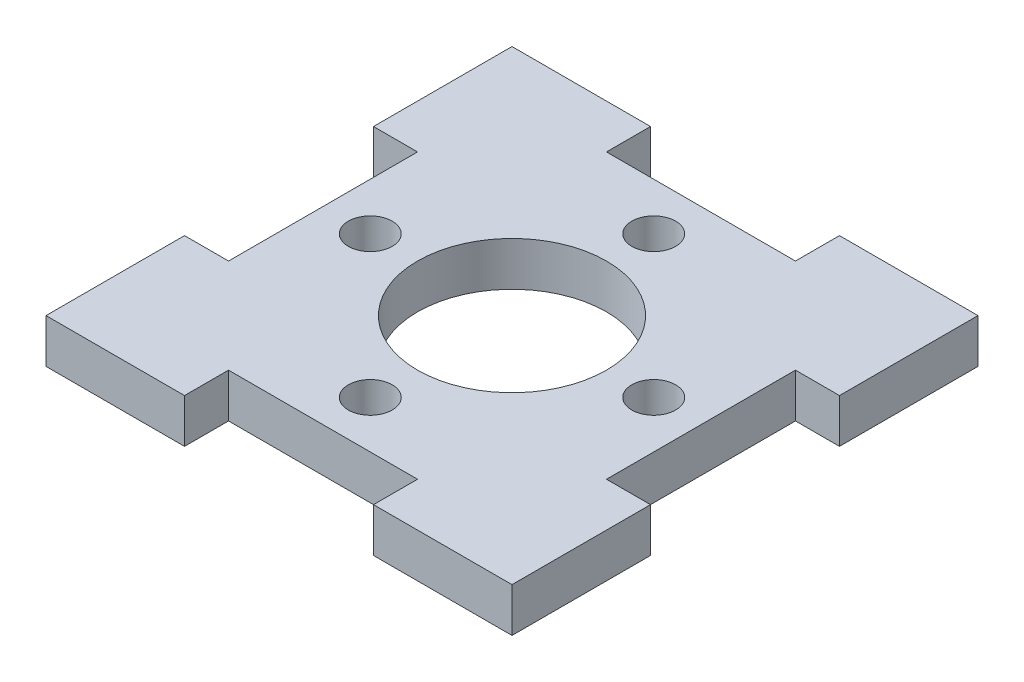
from build123d import *

# Parameters (mm, degrees)
SKETCH1_R                 = 6.35
BOSS_EXTRUDE1_DEPTH       = 2.9591
F_4_CLEARANCE_HOLE1_D     = 2.9464
F_4_CLEARANCE_HOLE1_DEPTH = 2.9591


with BuildPart() as part:
    # Sketch1 → Boss-Extrude1 (new body)
    with BuildSketch(Plane(origin=(0, 0, 0), x_dir=(1, 0, 0), z_dir=(0, 1, 0))):
        Polygon((6.35, 15.6591), (15.6591, 15.6591), (15.6591, 6.35), (12.7, 6.35), (12.7, -6.35), (15.6591, -6.35), (15.6591, -15.6591), (6.35, -15.6591), (6.35, -12.7), (-6.35, -12.7), (-6.35, -15.6591), (-15.6591, -15.6591), (-15.6591, -6.35), (-12.7, -6.35), (-12.7, 6.35), (-15.6591, 6.35), (-15.6591, 15.6591), (-6.35, 15.6591), (-6.35, 12.7), (6.35, 12.7), align=None)
        Circle(SKETCH1_R, mode=Mode.SUBTRACT)
    extrude(amount=BOSS_EXTRUDE1_DEPTH)

    # #4 Clearance Hole1
    with Locations(Plane(origin=(-7.797262335, 2.9591, -11.472083192), x_dir=(1, 0, 0), z_dir=(0, 1, 0))):
        with Locations((7.797262335, -1.947083192), (17.322262335, -11.472083192), (7.797262335, -20.997083192), (-1.727737665, -11.472083192)):
            Hole(F_4_CLEARANCE_HOLE1_D / 2, depth=F_4_CLEARANCE_HOLE1_DEPTH)


solid = part.part
